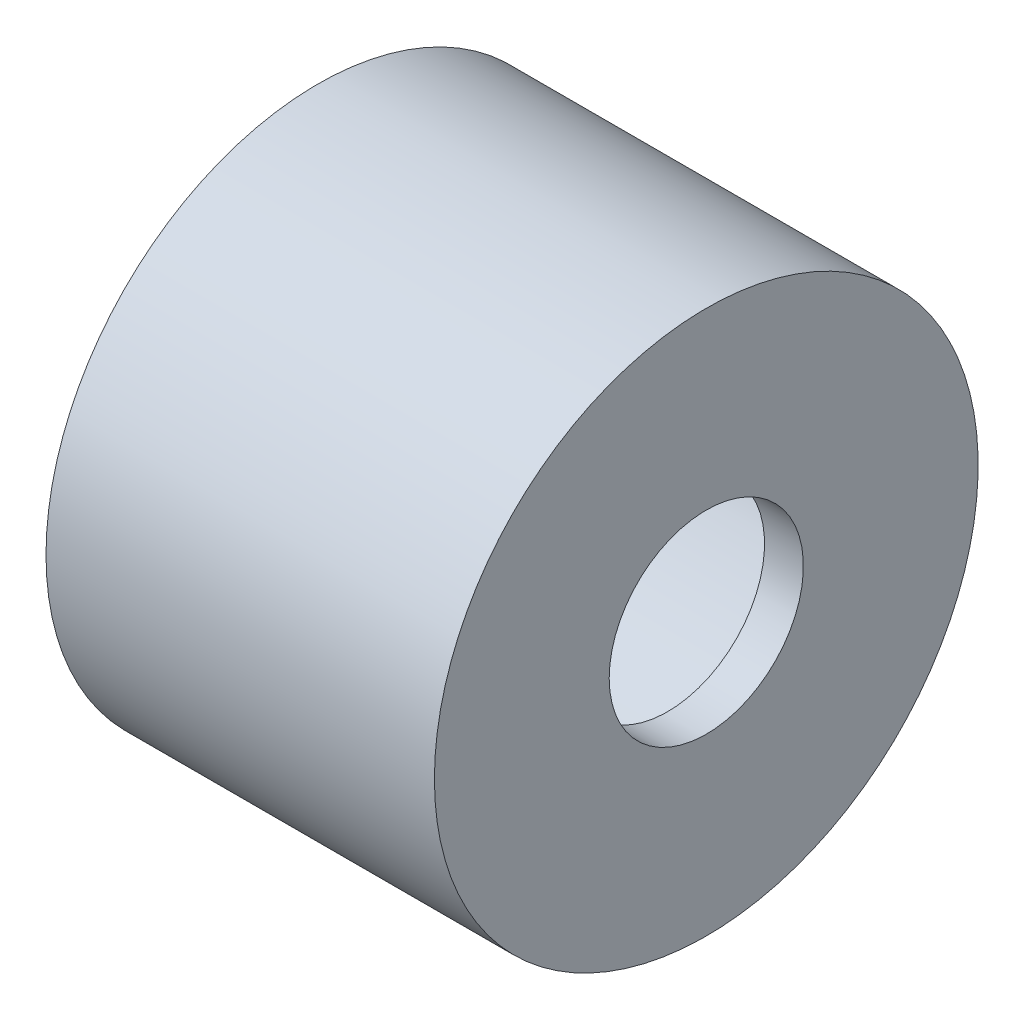
from build123d import *


with BuildPart() as part:
    # Sketch1 → Revolve1 (revolve)
    with BuildSketch(Plane.XY):
        Polygon((0, 7.62), (11.43, 7.62), (11.43, 3.175), (12.7, 3.175), (12.7, 8.89), (0, 8.89), align=None)
    revolve(axis=Axis((-0.305253565, 0, 0), (1, 0, 0)))


solid = part.part
